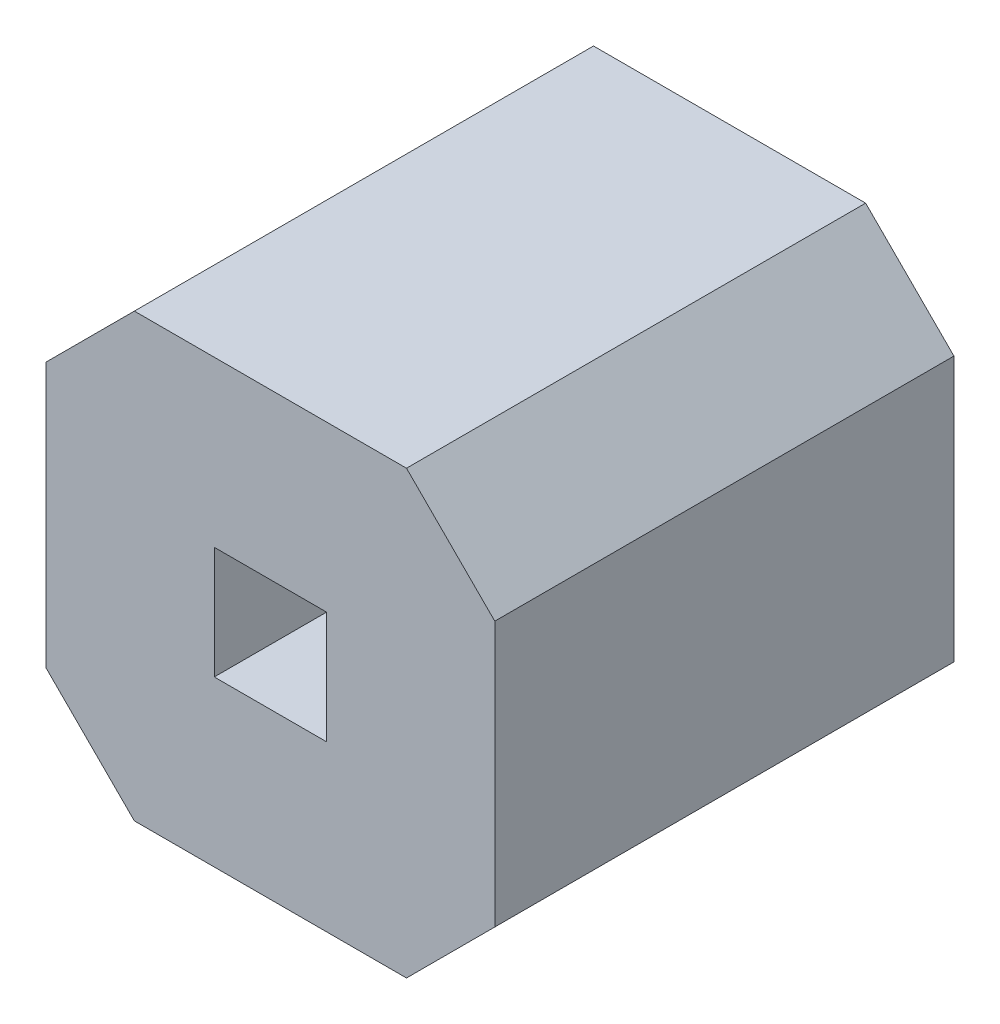
from build123d import *

# Parameters (mm, degrees)
CROQUIS1_W              = 2.541
CROQUIS1_H              = 2.5
CROQUIS1_W_2            = 0.636
CROQUIS1_H_2            = 0.636
SALIENTE_EXTRUIR2_DEPTH = 2.6
CHAFL_N2_SIZE           = 0.5


with BuildPart() as part:
    # Croquis1 → Saliente-Extruir2 (new body)
    with BuildSketch(Plane.XY):
        with Locations((1.2705, -1.25)):
            Rectangle(CROQUIS1_W, CROQUIS1_H)
        with Locations((1.2705, -1.25)):
            Rectangle(CROQUIS1_W_2, CROQUIS1_H_2, mode=Mode.SUBTRACT)
    extrude(amount=SALIENTE_EXTRUIR2_DEPTH)

    # Chaflán2
    chafl_n2_edges = [part.edges().sort_by_distance(p)[0] for p in [
        (0, 0, 1.3),
        (2.541, 0, 1.3),
        (2.541, -2.5, 1.3),
        (0, -2.5, 1.3),
    ]]
    chamfer(chafl_n2_edges, length=CHAFL_N2_SIZE)


solid = part.part
